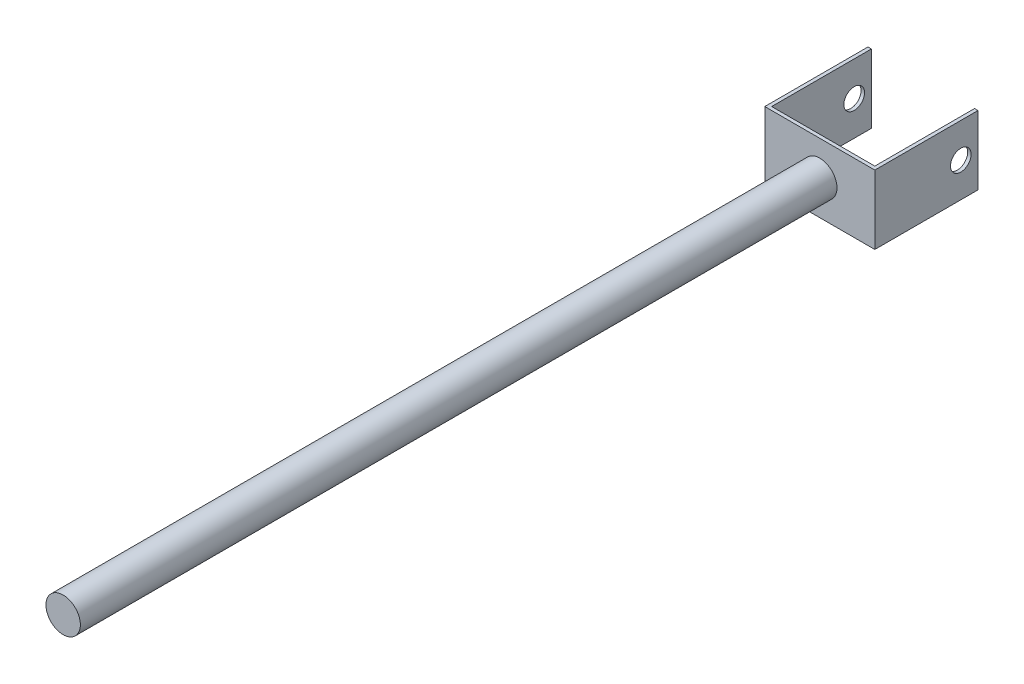
from build123d import *

# Parameters (mm, degrees)
BOSS_EXTRUDE3_DEPTH = 50
SKETCH4_R           = 25
BOSS_EXTRUDE4_DEPTH = 1100
SKETCH5_R           = 15
CUT_EXTRUDE1_DEPTH  = 161


with BuildPart() as part:
    # Sketch1 → Boss-Extrude3 (new body, symmetric)
    with BuildSketch(Plane(origin=(0, 0, 0), x_dir=(1, 0, 0), z_dir=(0, 1, 0))):
        Polygon((5, 150), (5, 5), (155, 5), (155, 150), (160, 150), (160, 0), (0, 0), (0, 150), align=None)
    extrude(amount=BOSS_EXTRUDE3_DEPTH, both=True)

    # Sketch4 → Boss-Extrude4 (add)
    with BuildSketch(Plane.XY):
        with Locations((80, 0)):
            Circle(SKETCH4_R)
    extrude(amount=BOSS_EXTRUDE4_DEPTH)

    # Sketch5 → Cut-Extrude1 (cut, through all)
    with BuildSketch(Plane(origin=(160, 0, 0), x_dir=(0, 0, -1), z_dir=(1, 0, 0))):
        with Locations((125, 0)):
            Circle(SKETCH5_R)
    extrude(amount=-CUT_EXTRUDE1_DEPTH, mode=Mode.SUBTRACT)


solid = part.part
